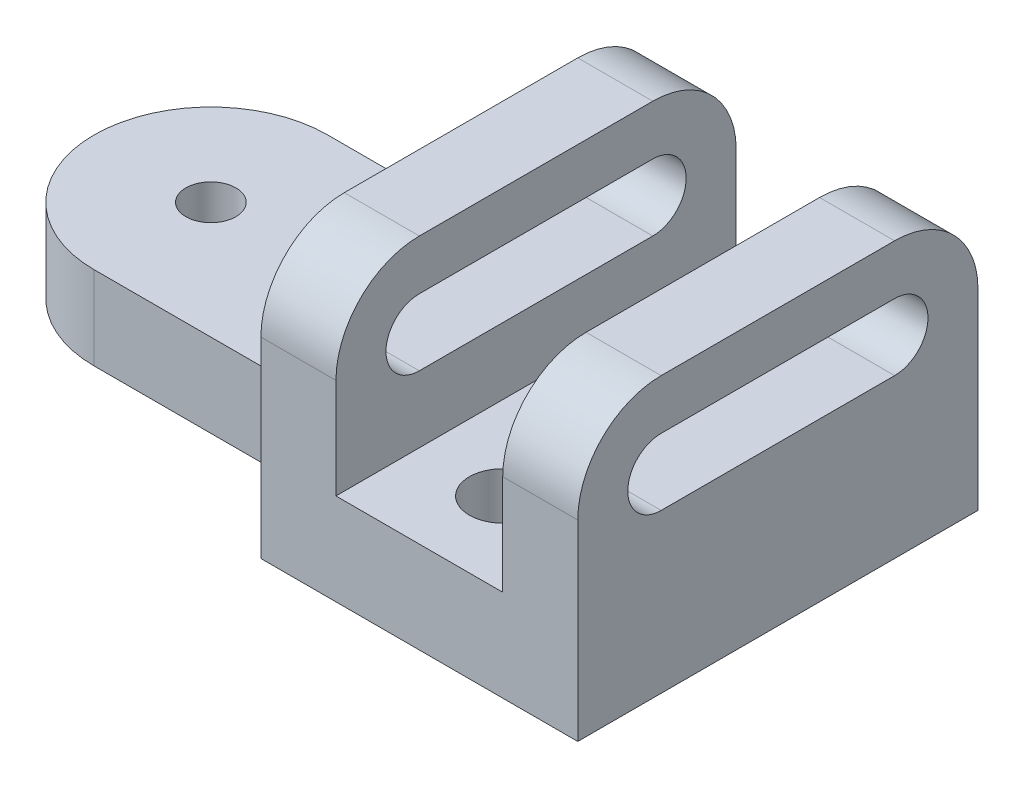
from build123d import *

# Parameters (mm, degrees)
BOSS_EXTRUDE1_DEPTH = 60.325
SKETCH5_W           = 31.75
SKETCH5_H           = 34.925
CUT_EXTRUDE1_DEPTH  = 77.2
BOSS_EXTRUDE2_DEPTH = 15.875
FILLET1_R           = 12.7
SKETCH7_R           = 6.35
CUT_EXTRUDE2_DEPTH  = 18.4625


with BuildPart() as part:
    # Sketch1 → Boss-Extrude1 (new body)
    with BuildSketch(Plane(origin=(0, 0, 0), x_dir=(0, 0, -1), z_dir=(1, 0, 0))):
        with BuildLine():
            Line((-60.325, 52.3875), (-15.875, 52.3875))
            ThreePointArc((-15.875, 52.3875), (-4.649679849, 47.737820151), (0, 36.5125))
            Line((0, 36.5125), (0, 0))
            Line((0, 0), (-76.2, 0))
            Line((-76.2, 0), (-76.2, 36.5125))
            ThreePointArc((-76.2, 36.5125), (-71.550320151, 47.737820151), (-60.325, 52.3875))
        make_face()
        with BuildLine():
            Line((-60.325, 42.8625), (-15.875, 42.8625))
            ThreePointArc((-15.875, 42.8625), (-9.525, 36.5125), (-15.875, 30.1625))
            Line((-15.875, 30.1625), (-60.325, 30.1625))
            ThreePointArc((-60.325, 30.1625), (-66.675, 36.5125), (-60.325, 42.8625))
        make_face(mode=Mode.SUBTRACT)
    extrude(amount=BOSS_EXTRUDE1_DEPTH)

    # Sketch5 → Cut-Extrude1 (cut, through all)
    with BuildSketch(Plane.XY.offset(76.2)):
        with Locations((30.1625, 34.925)):
            Rectangle(SKETCH5_W, SKETCH5_H)
    extrude(amount=-CUT_EXTRUDE1_DEPTH, mode=Mode.SUBTRACT)

    # Sketch6 → Boss-Extrude2 (add)
    with BuildSketch(Plane.XZ):
        with BuildLine():
            Line((0, 15.875), (0, 60.325))
            Line((0, 60.325), (-47.625, 60.325))
            ThreePointArc((-47.625, 60.325), (-31.909551788, 53.815448212), (-25.4, 38.1))
            ThreePointArc((-25.4, 38.1), (-31.909551788, 22.384551788), (-47.625, 15.875))
            Line((-47.625, 15.875), (0, 15.875))
        make_face()
        with BuildLine():
            ThreePointArc((-25.4, 38.1), (-31.909551788, 53.815448212), (-47.625, 60.325))
            Line((-47.625, 60.325), (-47.625, 42.8625))
            ThreePointArc((-47.625, 42.8625), (-44.257403955, 41.467596045), (-42.8625, 38.1))
            ThreePointArc((-42.8625, 38.1), (-44.257403955, 34.732403955), (-47.625, 33.3375))
            Line((-47.625, 33.3375), (-47.625, 15.875))
            ThreePointArc((-47.625, 15.875), (-31.909551788, 22.384551788), (-25.4, 38.1))
        make_face()
        with BuildLine():
            Line((-47.625, 42.8625), (-47.625, 60.325))
            ThreePointArc((-47.625, 60.325), (-69.85, 38.1), (-47.625, 15.875))
            Line((-47.625, 15.875), (-47.625, 33.3375))
            ThreePointArc((-47.625, 33.3375), (-52.3875, 38.1), (-47.625, 42.8625))
        make_face()
    extrude(amount=-BOSS_EXTRUDE2_DEPTH)

    # Fillet1
    fillet1_edges = [part.edges().sort_by_distance(p)[0] for p in [
        (0, 7.9375, 15.875),
        (0, 7.9375, 60.325),
    ]]
    fillet(fillet1_edges, radius=FILLET1_R)

    # Sketch7 → Cut-Extrude2 (cut, through all)
    with BuildSketch(Plane(origin=(0, 17.4625, 0), x_dir=(1, 0, 0), z_dir=(0, 1, 0))):
        with Locations((30.1625, -15.875)):
            Circle(SKETCH7_R)
        with Locations((30.1625, -60.325)):
            Circle(SKETCH7_R)
    extrude(amount=-CUT_EXTRUDE2_DEPTH, mode=Mode.SUBTRACT)


solid = part.part
